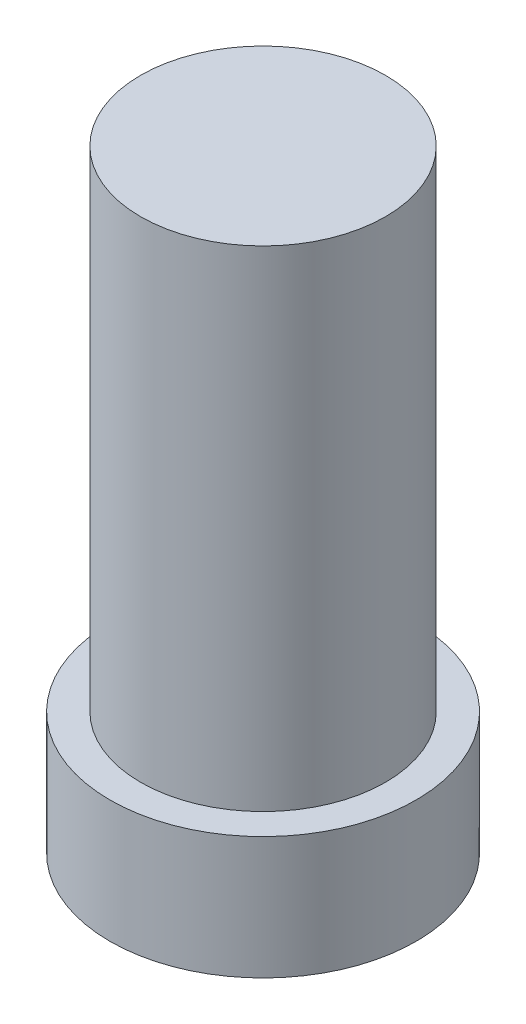
from build123d import *

# Parameters (mm, degrees)
SKETCH1_R           = 2.5
BOSS_EXTRUDE1_DEPTH = 2
SKETCH2_R           = 2
BOSS_EXTRUDE2_DEPTH = 8
SCALE1_SCALE        = 0.225


with BuildPart() as part:
    # Sketch1 → Boss-Extrude1 (new body)
    with BuildSketch(Plane(origin=(0, 0, 0), x_dir=(1, 0, 0), z_dir=(0, 1, 0))):
        Circle(SKETCH1_R)
    extrude(amount=BOSS_EXTRUDE1_DEPTH)

    # Sketch2 → Boss-Extrude2 (add)
    with BuildSketch(Plane(origin=(0, 2, 0), x_dir=(1, 0, 0), z_dir=(0, 1, 0))):
        Circle(SKETCH2_R)
    extrude(amount=BOSS_EXTRUDE2_DEPTH)


with BuildPart() as part_1:
    # Scale1: scaled about (0, 4.595505618, 0)
    add(part.part.scale(SCALE1_SCALE).moved(Location((0, 3.561516854, 0))))


solid = part_1.part
